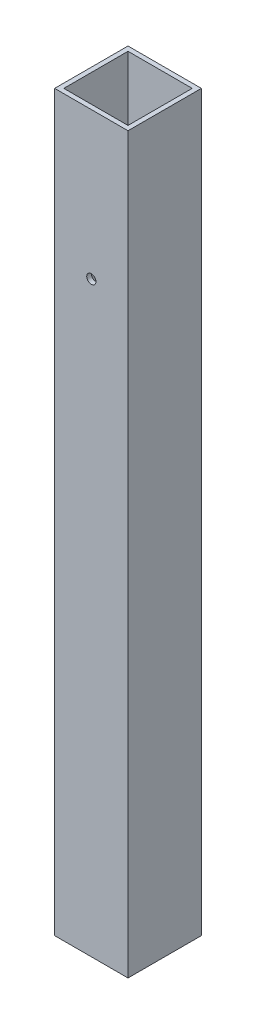
from build123d import *

# Parameters (mm, degrees)
SKETCH3_W           = 25.4
SKETCH3_H           = 25.4
SKETCH3_W_2         = 22.225
SKETCH3_H_2         = 22.225
BOSS_EXTRUDE1_DEPTH = 254
SKETCH4_R           = 1.5875
CUT_EXTRUDE1_DEPTH  = 26.4


with BuildPart() as part:
    # Sketch3 → Boss-Extrude1 (new body)
    with BuildSketch(Plane(origin=(0, 0, 0), x_dir=(1, 0, 0), z_dir=(0, 1, 0))):
        Rectangle(SKETCH3_W, SKETCH3_H)
        Rectangle(SKETCH3_W_2, SKETCH3_H_2, mode=Mode.SUBTRACT)
    extrude(amount=BOSS_EXTRUDE1_DEPTH)

    # Sketch4 → Cut-Extrude1 (cut, through all)
    with BuildSketch(Plane.XY.offset(12.7)):
        with Locations((0, 203.2)):
            Circle(SKETCH4_R)
    extrude(amount=-CUT_EXTRUDE1_DEPTH, mode=Mode.SUBTRACT)


solid = part.part
